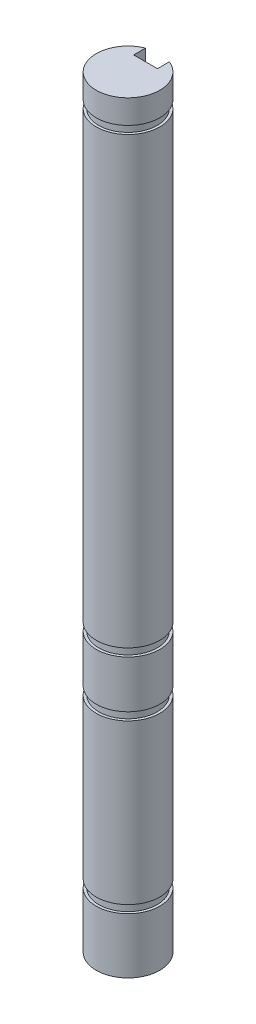
from build123d import *

# Parameters (mm, degrees)
BOSS_EXTRUDE1_DEPTH = 76.2
CUT_EXTRUDE1_START  = -3.175
SKETCH2_R           = 3.175
SKETCH2_R_2         = 2.921
CUT_EXTRUDE1_DEPTH  = 0.7874
CUT_EXTRUDE2_START  = -6.35
SKETCH3_R           = 3.175
SKETCH3_R_2         = 2.921
CUT_EXTRUDE2_DEPTH  = 0.7874
CUT_EXTRUDE3_START  = -23.04415
SKETCH3_5_R         = 3.175
SKETCH3_5_R_2       = 2.921
CUT_EXTRUDE3_DEPTH  = 0.7874
CUT_EXTRUDE4_START  = -28.575
SKETCH3_6_R         = 3.175
SKETCH3_6_R_2       = 2.921
CUT_EXTRUDE4_DEPTH  = 0.7874


with BuildPart() as part:
    # Sketch1 → Boss-Extrude1 (new body)
    with BuildSketch(Plane(origin=(0, 0, 0), x_dir=(1, 0, 0), z_dir=(0, 1, 0))):
        with BuildLine():
            Line((-1.190625, 2.943303775), (-1.190625, 1.752678775))
            Line((-1.190625, 1.752678775), (1.190625, 1.752678775))
            Line((1.190625, 1.752678775), (1.190625, 2.943303775))
            ThreePointArc((1.190625, 2.943303775), (0, -3.175), (-1.190625, 2.943303775))
        make_face()
    extrude(amount=BOSS_EXTRUDE1_DEPTH)

    # Sketch2 → Cut-Extrude1 (cut)
    with BuildSketch(Plane(origin=(0, 76.2, 0), x_dir=(1, 0, 0), z_dir=(0, 1, 0)).offset(CUT_EXTRUDE1_START)):
        Circle(SKETCH2_R)
        Circle(SKETCH2_R_2, mode=Mode.SUBTRACT)
    extrude(amount=CUT_EXTRUDE1_DEPTH, mode=Mode.SUBTRACT)

    # Sketch3 → Cut-Extrude2 (cut)
    with BuildSketch(Plane.XZ.offset(CUT_EXTRUDE2_START)):
        Circle(SKETCH3_R)
        Circle(SKETCH3_R_2, mode=Mode.SUBTRACT)
    extrude(amount=CUT_EXTRUDE2_DEPTH, mode=Mode.SUBTRACT)

    # Sketch3_5 → Cut-Extrude3 (cut)
    with BuildSketch(Plane.XZ.offset(CUT_EXTRUDE3_START)):
        Circle(SKETCH3_5_R)
        Circle(SKETCH3_5_R_2, mode=Mode.SUBTRACT)
    extrude(amount=CUT_EXTRUDE3_DEPTH, mode=Mode.SUBTRACT)

    # Sketch3_6 → Cut-Extrude4 (cut)
    with BuildSketch(Plane.XZ.offset(CUT_EXTRUDE4_START)):
        Circle(SKETCH3_6_R)
        Circle(SKETCH3_6_R_2, mode=Mode.SUBTRACT)
    extrude(amount=CUT_EXTRUDE4_DEPTH, mode=Mode.SUBTRACT)


solid = part.part
